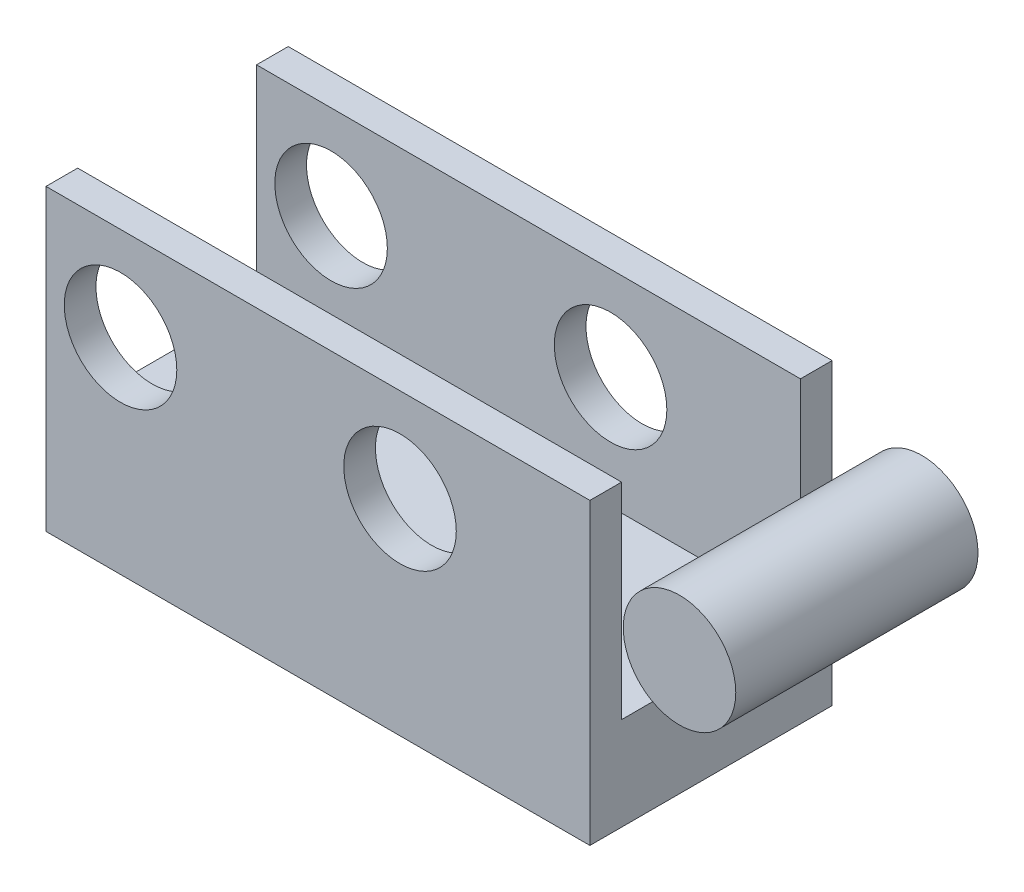
from build123d import *

# Parameters (mm, degrees)
SKETCH2_R             = 1.51
BOSS_EXTRUDE2_DEPTH   = 3.25
SKETCH2_W             = 14.59562339
SKETCH2_H             = 8.02
BOSS_EXTRUDE2_2_DEPTH = 3.25
SKETCH3_W             = 14.59562339
SKETCH3_H             = 5.52
CUT_EXTRUDE4_DEPTH    = 2.4


with BuildPart() as part:
    # Sketch2 → Boss-Extrude2 (new body, symmetric)
    with BuildSketch(Plane.XY):
        with Locations((9.702188305, -2.140747254)):
            Circle(SKETCH2_R)
    extrude(amount=BOSS_EXTRUDE2_DEPTH, both=True)


with BuildPart() as body_2:
    # Sketch2 → Boss-Extrude2 2 (new body, symmetric)
    with BuildSketch(Plane.XY):
        with Locations((0, -3.640747254)):
            Rectangle(SKETCH2_W, SKETCH2_H)
        with Locations((-5.297811695, -2.140747254)):
            Circle(SKETCH2_R, mode=Mode.SUBTRACT)
        with Locations((2.202188305, -2.140747254)):
            Circle(SKETCH2_R, mode=Mode.SUBTRACT)
    extrude(amount=BOSS_EXTRUDE2_2_DEPTH, both=True)

    # Sketch3 → Cut-Extrude4 (cut, symmetric)
    with BuildSketch(Plane.XY):
        with Locations((0, -2.390747254)):
            Rectangle(SKETCH3_W, SKETCH3_H)
    extrude(amount=CUT_EXTRUDE4_DEPTH, both=True, mode=Mode.SUBTRACT)


solid = Compound([part.part, body_2.part])
